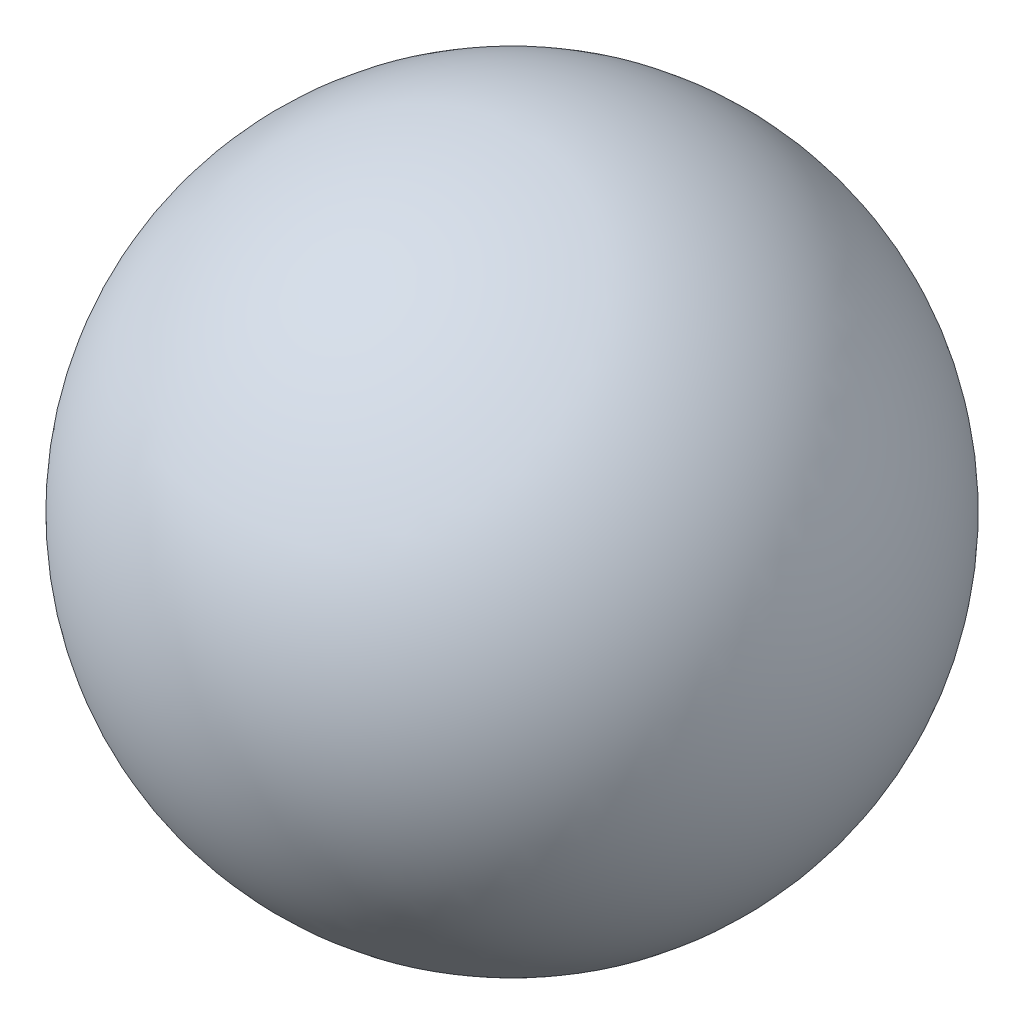
from build123d import *


with BuildPart() as part:
    # Sketch1 → Revolve1 (revolve)
    with BuildSketch(Plane.XY):
        with BuildLine():
            Line((0, 125), (0, 105))
            ThreePointArc((0, 105), (105, 0), (0, -105))
            Line((0, -105), (0, -125))
            ThreePointArc((0, -125), (125, 0), (0, 125))
        make_face()
    revolve(axis=Axis((0, 105, 0), (0, -1, 0)))


solid = part.part
